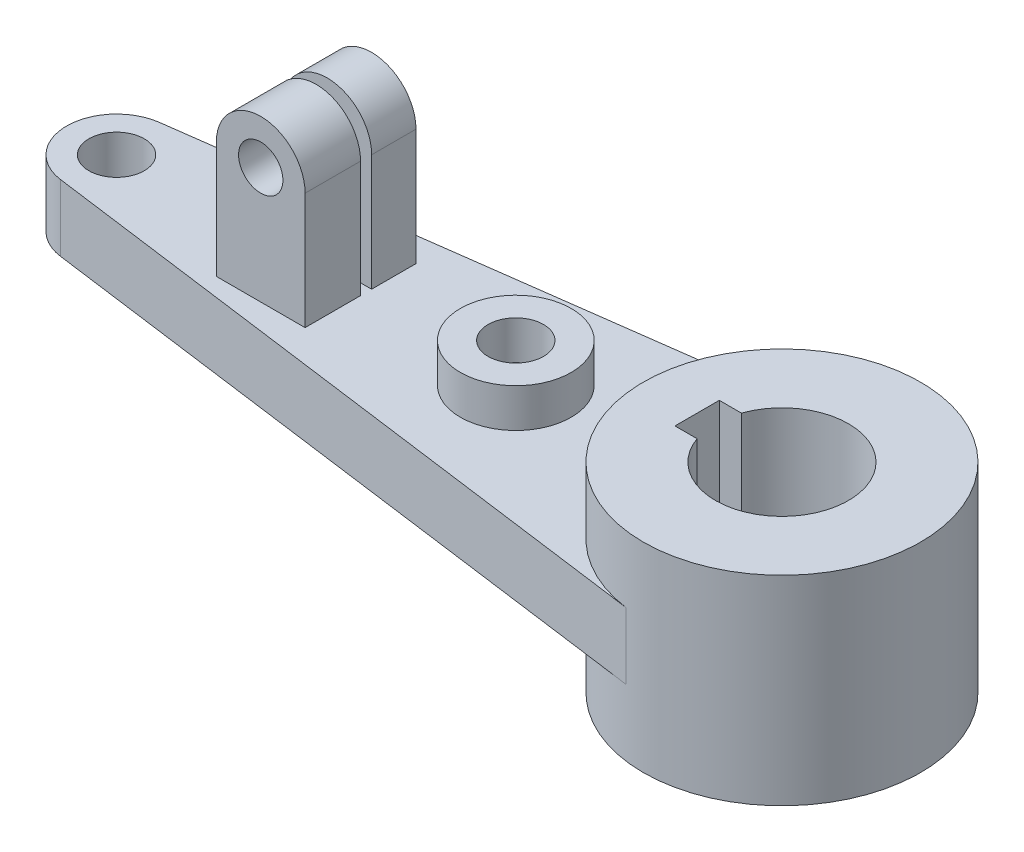
from build123d import *

# Parameters (mm, degrees)
IZIM1_R                     = 25
Y_KSEKLIK_EKSTR_ZYON1_DEPTH = 18
IZIM2_R                     = 5
Y_KSEKLIK_EKSTR_ZYON2_DEPTH = 6
IZIM3_R                     = 10
Y_KSEKLIK_EKSTR_ZYON3_DEPTH = 7
IZIM4_R                     = 5
KES_EKSTR_ZYON1_DEPTH       = 7
IZIM9_R                     = 4
Y_KSEKLIK_EKSTR_ZYON5_DEPTH = 10
KES_EKSTR_ZYON2_DEPTH       = 16


with BuildPart() as part:
    # Çizim1 → Yükseklik-Ekstrüzyon1 (new body, symmetric)
    with BuildSketch(Plane(origin=(0, 0, 0), x_dir=(1, 0, 0), z_dir=(0, 1, 0))):
        Circle(IZIM1_R)
        with BuildLine():
            Line((-15.3, 4), (-11.313708499, 4))
            ThreePointArc((-11.313708499, 4), (12, 0), (-11.313708499, -4))
            Line((-11.313708499, -4), (-15.3, -4))
            Line((-15.3, -4), (-15.3, 4))
        make_face(mode=Mode.SUBTRACT)
    extrude(amount=Y_KSEKLIK_EKSTR_ZYON1_DEPTH, both=True)

    # Çizim2 → Yükseklik-Ekstrüzyon2 (add, symmetric)
    with BuildSketch(Plane(origin=(0, 0, 0), x_dir=(1, 0, 0), z_dir=(0, 1, 0))):
        with BuildLine():
            Line((-121.2, -8.919641248), (-3.333333333, -24.776781246))
            ThreePointArc((-3.333333333, -24.776781246), (-25, 0), (-3.333333333, 24.776781246))
            Line((-3.333333333, 24.776781246), (-121.2, 8.919641248))
            ThreePointArc((-121.2, 8.919641248), (-129, 0), (-121.2, -8.919641248))
        make_face()
        with Locations((-120, 0)):
            Circle(IZIM2_R, mode=Mode.SUBTRACT)
    extrude(amount=Y_KSEKLIK_EKSTR_ZYON2_DEPTH, both=True)

    # Çizim3 → Yükseklik-Ekstrüzyon3 (add)
    with BuildSketch(Plane(origin=(0, 6, 0), x_dir=(1, 0, 0), z_dir=(0, 1, 0))):
        with Locations((-48, 0)):
            Circle(IZIM3_R)
    extrude(amount=Y_KSEKLIK_EKSTR_ZYON3_DEPTH)

    # Çizim4 → Kes-Ekstrüzyon1 (cut)
    with BuildSketch(Plane(origin=(0, 13, 0), x_dir=(1, 0, 0), z_dir=(0, 1, 0))):
        with Locations((-48, 0)):
            Circle(IZIM4_R)
    extrude(amount=-KES_EKSTR_ZYON1_DEPTH, mode=Mode.SUBTRACT)

    # Çizim9 → Yükseklik-Ekstrüzyon5 (add, symmetric)
    with BuildSketch(Plane.XY):
        with BuildLine():
            Line((-76, 27), (-76, 6))
            Line((-76, 6), (-92, 6))
            Line((-92, 6), (-92, 27))
            ThreePointArc((-92, 27), (-84, 35), (-76, 27))
        make_face()
        with Locations((-84, 27)):
            Circle(IZIM9_R, mode=Mode.SUBTRACT)
    extrude(amount=Y_KSEKLIK_EKSTR_ZYON5_DEPTH, both=True)

    # Çizim10 → Kes-Ekstrüzyon2 (cut)
    with BuildSketch(Plane.ZY.offset(92)):
        Polygon((0, 6), (-2, 6), (-2, 27), (-2, 35), (0, 35), (0, 27), align=None)
    extrude(amount=-KES_EKSTR_ZYON2_DEPTH, mode=Mode.SUBTRACT)


solid = part.part
